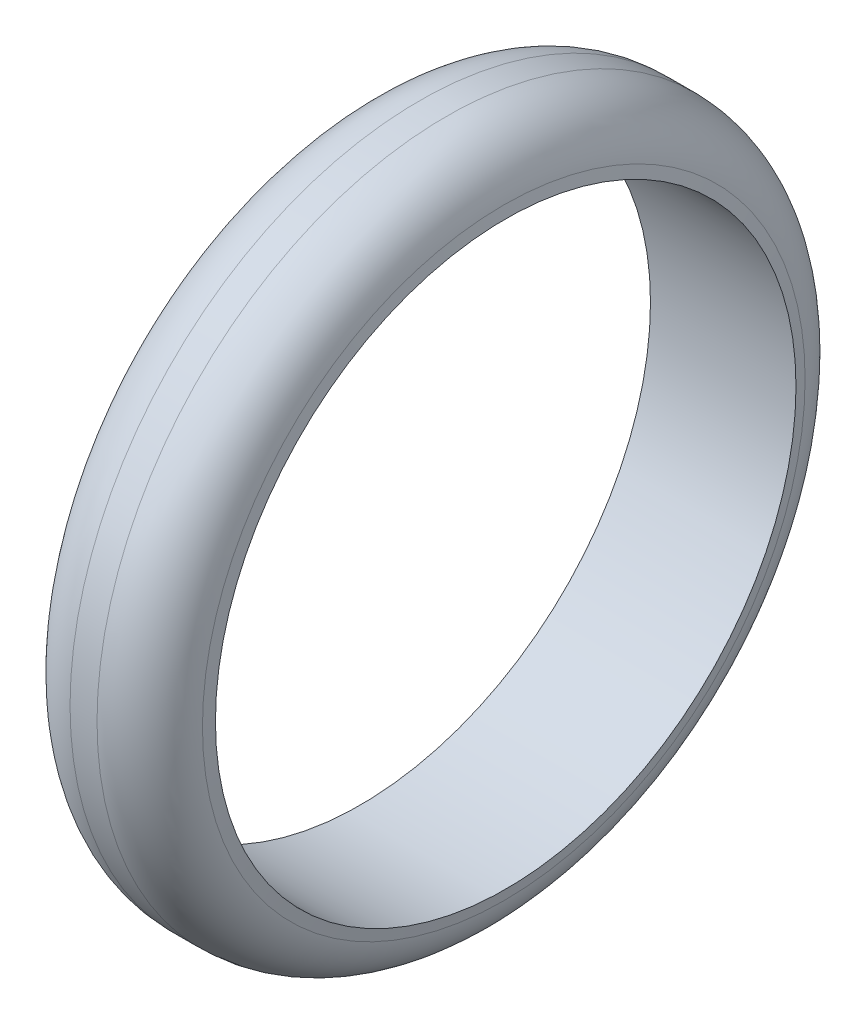
from build123d import *

# Parameters (mm, degrees)
FILLET1_R = 8
FILLET2_R = 8


with BuildPart() as part:
    # Sketch1 → Revolve8 (revolve)
    with BuildSketch(Plane.XY):
        Polygon((-8.566656945, 48.024560211), (8.566656945, 48.024560211), (10, 39.895667803), (-10, 39.895667803), align=None)
    revolve(axis=Axis((0, 0, 0), (1, 0, 0)))

    # Fillet1
    fillet1_edges = [part.edges().sort_by_distance(p)[0] for p in [
        (-8.566656945, -48.024560211, 0),
    ]]
    fillet(fillet1_edges, radius=FILLET1_R)

    # Fillet2
    fillet2_edges = [part.edges().sort_by_distance(p)[0] for p in [
        (8.566656945, -48.024560211, 0),
    ]]
    fillet(fillet2_edges, radius=FILLET2_R)


solid = part.part
